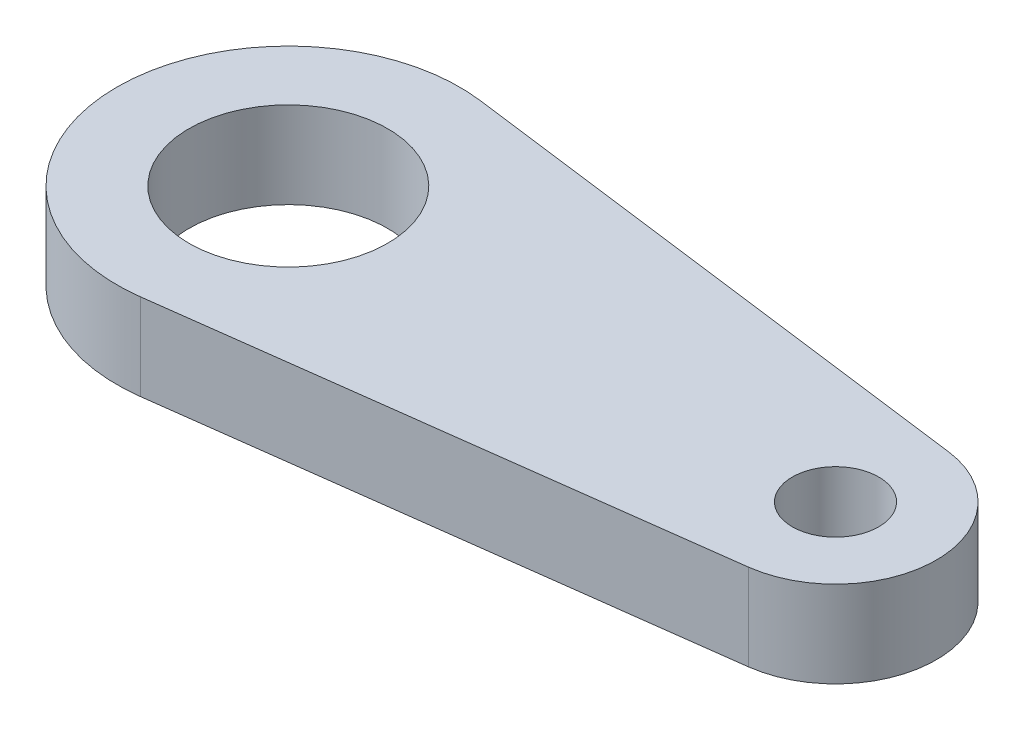
from build123d import *

# Parameters (mm, degrees)
SKETCH1_R           = 1.5
SKETCH1_R_2         = 3.45
BOSS_EXTRUDE1_DEPTH = 1.5


with BuildPart() as part:
    # Sketch1 → Boss-Extrude1 (new body, symmetric)
    with BuildSketch(Plane(origin=(0, 0, 0), x_dir=(1, 0, 0), z_dir=(0, 1, 0))):
        with BuildLine():
            Line((19.451315789, 3.470780036), (0.767236842, 5.900326061))
            ThreePointArc((0.767236842, 5.900326061), (-5.95, 0), (0.767236842, -5.900326061))
            Line((0.767236842, -5.900326061), (19.451315789, -3.470780036))
            ThreePointArc((19.451315789, -3.470780036), (22.5, 0), (19.451315789, 3.470780036))
        make_face()
        with Locations((19, 0)):
            Circle(SKETCH1_R, mode=Mode.SUBTRACT)
        Circle(SKETCH1_R_2, mode=Mode.SUBTRACT)
    extrude(amount=BOSS_EXTRUDE1_DEPTH, both=True)


solid = part.part
